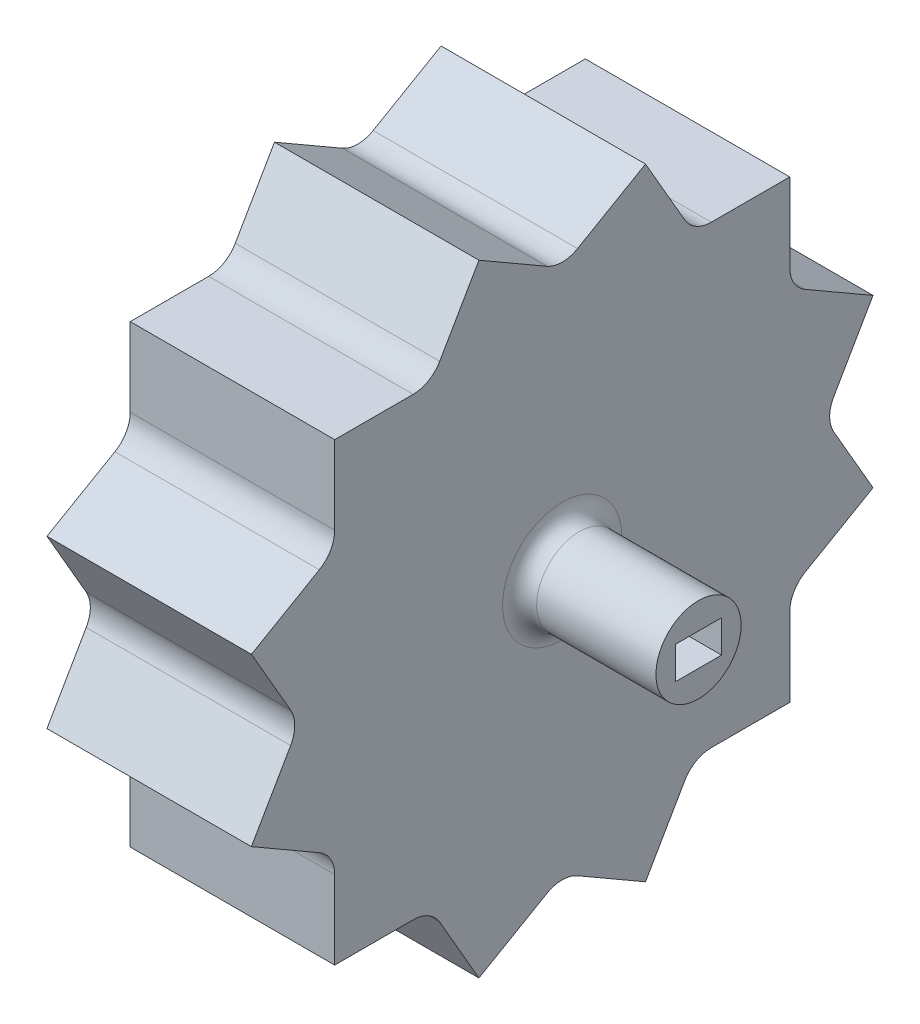
from build123d import *

# Parameters (mm, degrees)
BOSS_EXTRUDE1_DEPTH = 24
SKETCH2_R           = 5
BOSS_EXTRUDE2_DEPTH = 16
FILLET1_R           = 2
SKETCH4_W           = 5.41
SKETCH4_H           = 3.8
CUT_EXTRUDE1_DEPTH  = 20


with BuildPart() as part:
    # Sketch1 → Boss-Extrude1 (new body)
    with BuildSketch(Plane(origin=(0, 0, 0), x_dir=(0, 0, -1), z_dir=(1, 0, 0))):
        with BuildLine():
            Line((1.8, 31.882308546), (9.77686398, 36.487753113))
            Line((9.77686398, 36.487753113), (14.382308546, 28.510889132))
            ThreePointArc((14.382308546, 28.510889132), (15.7, 27.193197679), (17.5, 26.710889132))
            Line((17.5, 26.710889132), (26.710889132, 26.710889132))
            Line((26.710889132, 26.710889132), (26.710889132, 17.5))
            ThreePointArc((26.710889132, 17.5), (27.193197679, 15.7), (28.510889132, 14.382308546))
            Line((28.510889132, 14.382308546), (36.487753113, 9.77686398))
            Line((36.487753113, 9.77686398), (31.882308546, 1.8))
            ThreePointArc((31.882308546, 1.8), (31.4, 0), (31.882308546, -1.8))
            Line((31.882308546, -1.8), (36.487753113, -9.77686398))
            Line((36.487753113, -9.77686398), (28.510889132, -14.382308546))
            ThreePointArc((28.510889132, -14.382308546), (27.193197679, -15.7), (26.710889132, -17.5))
            Line((26.710889132, -17.5), (26.710889132, -26.710889132))
            Line((26.710889132, -26.710889132), (17.5, -26.710889132))
            ThreePointArc((17.5, -26.710889132), (15.7, -27.193197679), (14.382308546, -28.510889132))
            Line((14.382308546, -28.510889132), (9.77686398, -36.487753113))
            Line((9.77686398, -36.487753113), (1.8, -31.882308546))
            ThreePointArc((1.8, -31.882308546), (0, -31.4), (-1.8, -31.882308546))
            Line((-1.8, -31.882308546), (-9.77686398, -36.487753113))
            Line((-9.77686398, -36.487753113), (-14.382308546, -28.510889132))
            ThreePointArc((-14.382308546, -28.510889132), (-15.7, -27.193197679), (-17.5, -26.710889132))
            Line((-17.5, -26.710889132), (-26.710889132, -26.710889132))
            Line((-26.710889132, -26.710889132), (-26.710889132, -17.5))
            ThreePointArc((-26.710889132, -17.5), (-27.193197679, -15.7), (-28.510889132, -14.382308546))
            Line((-28.510889132, -14.382308546), (-36.487753113, -9.77686398))
            Line((-36.487753113, -9.77686398), (-31.882308546, -1.8))
            ThreePointArc((-31.882308546, -1.8), (-31.4, 0), (-31.882308546, 1.8))
            Line((-31.882308546, 1.8), (-36.487753113, 9.77686398))
            Line((-36.487753113, 9.77686398), (-28.510889132, 14.382308546))
            ThreePointArc((-28.510889132, 14.382308546), (-27.193197679, 15.7), (-26.710889132, 17.5))
            Line((-26.710889132, 17.5), (-26.710889132, 26.710889132))
            Line((-26.710889132, 26.710889132), (-17.5, 26.710889132))
            ThreePointArc((-17.5, 26.710889132), (-15.7, 27.193197679), (-14.382308546, 28.510889132))
            Line((-14.382308546, 28.510889132), (-9.77686398, 36.487753113))
            Line((-9.77686398, 36.487753113), (-1.8, 31.882308546))
            ThreePointArc((-1.8, 31.882308546), (0, 31.4), (1.8, 31.882308546))
        make_face()
    extrude(amount=BOSS_EXTRUDE1_DEPTH)

    # Sketch2 → Boss-Extrude2 (add)
    with BuildSketch(Plane(origin=(24, 0, 0), x_dir=(0, 0, -1), z_dir=(1, 0, 0))):
        Circle(SKETCH2_R)
    extrude(amount=BOSS_EXTRUDE2_DEPTH)

    # Fillet1
    fillet1_edges = [part.edges().sort_by_distance(p)[0] for p in [
        (24, 0, 5),
    ]]
    fillet(fillet1_edges, radius=FILLET1_R)

    # Sketch4 → Cut-Extrude1 (cut)
    with BuildSketch(Plane(origin=(40, 0, 0), x_dir=(0, 0, -1), z_dir=(1, 0, 0))):
        Rectangle(SKETCH4_W, SKETCH4_H)
    extrude(amount=-CUT_EXTRUDE1_DEPTH, mode=Mode.SUBTRACT)


solid = part.part
